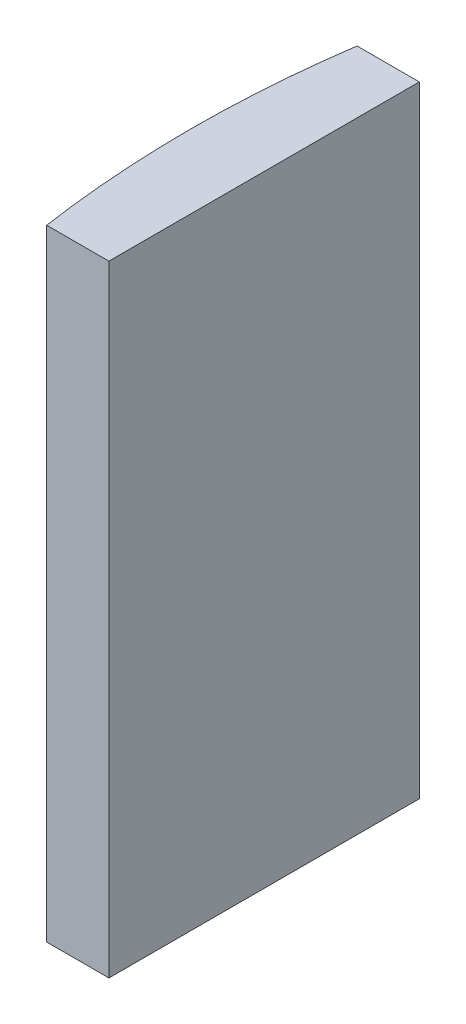
from build123d import *

# Parameters (mm, degrees)
EXTRUDE_1_DEPTH = 20


with BuildPart() as part:
    # 草图1 → 凸台-拉伸1 (new body)
    with BuildSketch(Plane(origin=(0, 0, 0), x_dir=(1, 0, 0), z_dir=(0, 1, 0))):
        with BuildLine():
            Line((-29.628946383, 5), (-27.624795665, 5))
            Line((-27.624795665, 5), (-27.624795665, -5))
            Line((-27.624795665, -5), (-29.628946383, -5))
            ThreePointArc((-29.628946383, -5), (-29.994795665, 0), (-29.628946383, 5))
        make_face()
    extrude(amount=EXTRUDE_1_DEPTH)


solid = part.part
